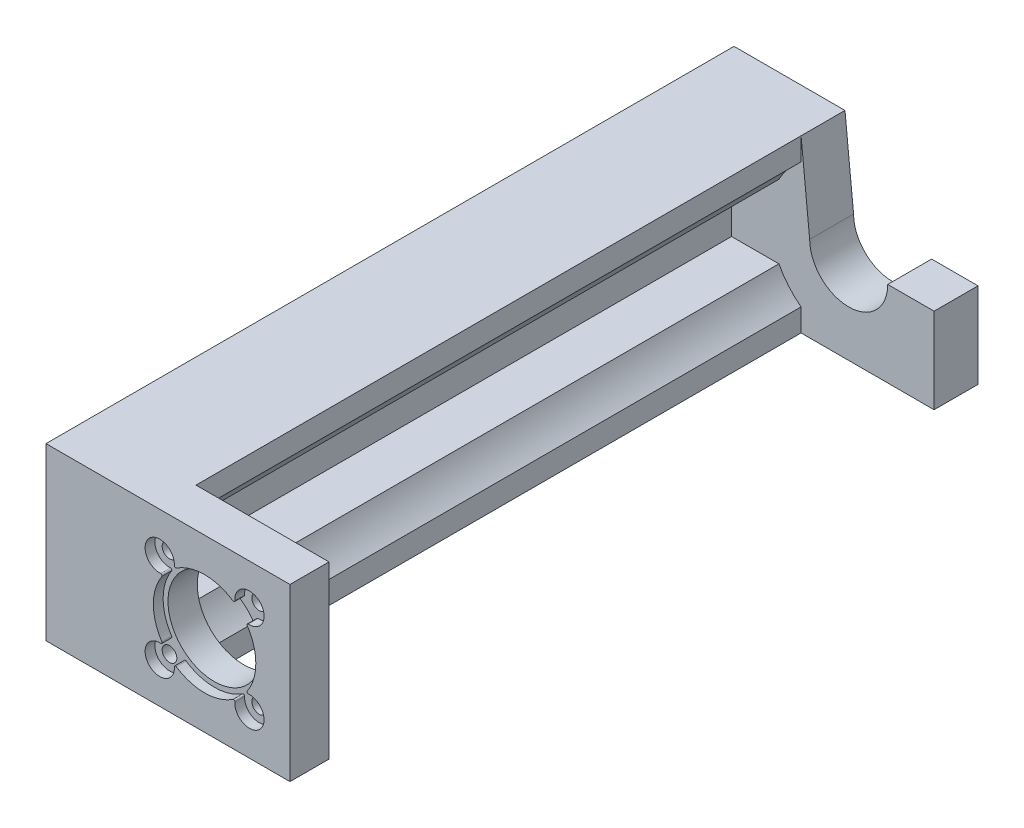
from build123d import *

# Parameters (mm, degrees)
SKETCH1_W           = 50
SKETCH1_H           = 35
SKETCH1_R           = 9.5
SKETCH1_R_2         = 1.5
BOSS_EXTRUDE3_DEPTH = 6
SKETCH4_W           = 50
SKETCH4_H           = 35
BOSS_EXTRUDE5_DEPTH = 2
BOSS_EXTRUDE6_DEPTH = 124
SKETCH9_R           = 2
CUT_EXTRUDE1_DEPTH  = 115
BOSS_EXTRUDE7_DEPTH = 9


with BuildPart() as part:
    # Sketch1 → Boss-Extrude3 (new body)
    with BuildSketch(Plane.XY):
        with Locations((25, 17.5)):
            Rectangle(SKETCH1_W, SKETCH1_H)
        with Locations((32.5, 17.5)):
            Circle(SKETCH1_R, mode=Mode.SUBTRACT)
        with Locations((41.692388155, 26.692388155)):
            Circle(SKETCH1_R_2, mode=Mode.SUBTRACT)
        with Locations((41.692388155, 8.307611845)):
            Circle(SKETCH1_R_2, mode=Mode.SUBTRACT)
        with Locations((23.307611845, 8.307611845)):
            Circle(SKETCH1_R_2, mode=Mode.SUBTRACT)
        with Locations((23.307611845, 26.692388155)):
            Circle(SKETCH1_R_2, mode=Mode.SUBTRACT)
    extrude(amount=BOSS_EXTRUDE3_DEPTH)

    # Sketch4 → Boss-Extrude5 (add)
    with BuildSketch(Plane.XY.offset(6)):
        with Locations((25, 17.5)):
            Rectangle(SKETCH4_W, SKETCH4_H)
        with BuildLine():
            ThreePointArc((26.299419693, 26.47083501), (21.186291501, 28.813708499), (23.52916499, 23.700580307))
            ThreePointArc((23.52916499, 23.700580307), (23.763454109, 23.57743344), (23.755822455, 23.312861521))
            ThreePointArc((23.755822455, 23.312861521), (22, 17.5), (23.755822455, 11.687138479))
            ThreePointArc((23.755822455, 11.687138479), (23.763454109, 11.42256656), (23.52916499, 11.299419693))
            ThreePointArc((23.52916499, 11.299419693), (21.186291501, 6.186291501), (26.299419693, 8.52916499))
            ThreePointArc((26.299419693, 8.52916499), (26.42256656, 8.763454109), (26.687138479, 8.755822455))
            ThreePointArc((26.687138479, 8.755822455), (32.5, 7), (38.312861521, 8.755822455))
            ThreePointArc((38.312861521, 8.755822455), (38.57743344, 8.763454109), (38.700580307, 8.52916499))
            ThreePointArc((38.700580307, 8.52916499), (43.813708499, 6.186291501), (41.47083501, 11.299419693))
            ThreePointArc((41.47083501, 11.299419693), (41.236545891, 11.42256656), (41.244177545, 11.687138479))
            ThreePointArc((41.244177545, 11.687138479), (43, 17.5), (41.244177545, 23.312861521))
            ThreePointArc((41.244177545, 23.312861521), (41.236545891, 23.57743344), (41.47083501, 23.700580307))
            ThreePointArc((41.47083501, 23.700580307), (43.813708499, 28.813708499), (38.700580307, 26.47083501))
            ThreePointArc((38.700580307, 26.47083501), (38.57743344, 26.236545891), (38.312861521, 26.244177545))
            ThreePointArc((38.312861521, 26.244177545), (32.5, 28), (26.687138479, 26.244177545))
            ThreePointArc((26.687138479, 26.244177545), (26.42256656, 26.236545891), (26.299419693, 26.47083501))
        make_face(mode=Mode.SUBTRACT)
    extrude(amount=BOSS_EXTRUDE5_DEPTH)

    # Sketch8 → Boss-Extrude6 (add)
    with BuildSketch(Plane(origin=(0, 0, 0), x_dir=(-1, 0, 0), z_dir=(0, 0, -1))):
        with BuildLine():
            Line((-8.5, 35), (-22.740329685, 35))
            Line((-22.740329685, 35), (-22.740329685, 30.367452558))
            ThreePointArc((-22.740329685, 30.367452558), (-20.171344576, 27.9320063), (-18.194683381, 24.99535966))
            Line((-18.194683381, 24.99535966), (-18.194683381, 25))
            Line((-18.194683381, 25), (-8.5, 25))
            Line((-8.5, 25), (-8.5, 10.000000197))
            Line((-8.5, 10.000000197), (-18.197115572, 10.000000197))
            ThreePointArc((-18.197115572, 10.000000197), (-20.17303677, 7.065994176), (-22.740329685, 4.632547442))
            Line((-22.740329685, 4.632547442), (-22.740329685, 0))
            Line((-22.740329685, 0), (-8.5, 0))
            Line((-8.5, 0), (0, 0))
            Line((0, 0), (0, 10.000000197))
            Line((0, 10.000000197), (0, 25))
            Line((0, 25), (0, 35))
            Line((0, 35), (-8.5, 35))
        make_face()
    extrude(amount=BOSS_EXTRUDE6_DEPTH)

    # Sketch9 → Cut-Extrude1 (cut)
    with BuildSketch(Plane.ZY):
        with Locations((-7, 17.5)):
            Circle(SKETCH9_R)
        with Locations((-24, 17.5)):
            Circle(SKETCH9_R)
        with Locations((-41, 17.5)):
            Circle(SKETCH9_R)
        with Locations((-58, 17.5)):
            Circle(SKETCH9_R)
        with Locations((-75, 17.5)):
            Circle(SKETCH9_R)
        with Locations((-92, 17.5)):
            Circle(SKETCH9_R)
        with Locations((-109, 17.5)):
            Circle(SKETCH9_R)
    extrude(amount=-CUT_EXTRUDE1_DEPTH, mode=Mode.SUBTRACT)

    # Sketch12 → Boss-Extrude7 (add)
    with BuildSketch(Plane(origin=(0, 0, -124), x_dir=(-1, 0, 0), z_dir=(0, 0, -1))):
        with BuildLine():
            Line((-24.5, 17.5), (-22.740329685, 35))
            Line((-22.740329685, 35), (0, 35))
            Line((0, 35), (0, 0))
            Line((0, 0), (-50, 0))
            Line((-50, 0), (-50, 17.5))
            Line((-50, 17.5), (-40.5, 17.5))
            ThreePointArc((-40.5, 17.5), (-32.5, 9.5), (-24.5, 17.5))
        make_face()
    extrude(amount=BOSS_EXTRUDE7_DEPTH)


solid = part.part
